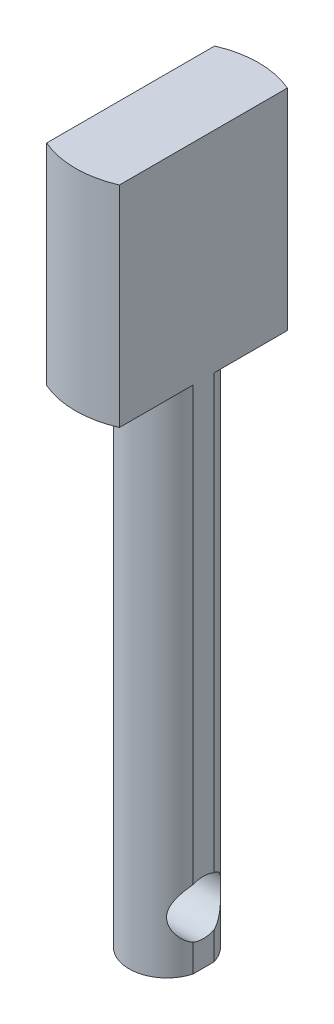
from build123d import *

# Parameters (mm, degrees)
SKETCH1_R               = 2.525
BOSS_EXTRUDE1_DEPTH     = 48
SKETCH2_R               = 6.1
BOSS_EXTRUDE2_DEPTH     = 14
SKETCH3_R               = 1.8
CUT_EXTRUDE1_DEPTH      = 7.1
CUT_EXTRUDE1_DEPTH_BACK = 7.1
SKETCH4_OUTSIDE_W       = 24.402
SKETCH4_OUTSIDE_H       = 24.402
SKETCH4_OUTSIDE_W_2     = 4.85
SKETCH4_OUTSIDE_H_2     = 23.377611606
CUT_EXTRUDE4_DEPTH      = 49


with BuildPart() as part:
    # Sketch1 → Boss-Extrude1 (new body)
    with BuildSketch(Plane(origin=(0, 0, 0), x_dir=(1, 0, 0), z_dir=(0, 1, 0))):
        Circle(SKETCH1_R)
    extrude(amount=BOSS_EXTRUDE1_DEPTH)

    # Sketch2 → Boss-Extrude2 (add)
    with BuildSketch(Plane(origin=(0, 48, 0), x_dir=(1, 0, 0), z_dir=(0, 1, 0))):
        Circle(SKETCH2_R)
    extrude(amount=-BOSS_EXTRUDE2_DEPTH)

    # Sketch3 → Cut-Extrude1 (cut, two sides)
    with BuildSketch(Plane(origin=(0, 0, 0), x_dir=(0, 0, -1), z_dir=(1, 0, 0))) as cut_extrude1_sk:
        with Locations((0, 3.5)):
            Circle(SKETCH3_R)
    extrude(amount=CUT_EXTRUDE1_DEPTH, mode=Mode.SUBTRACT)
    extrude(cut_extrude1_sk.sketch, amount=-CUT_EXTRUDE1_DEPTH_BACK, mode=Mode.SUBTRACT)

    # Sketch4 outside → Cut-Extrude4 (cut, through all)
    with BuildSketch(Plane(origin=(0, 0, 0), x_dir=(1, 0, 0), z_dir=(0, 1, 0))):
        Rectangle(SKETCH4_OUTSIDE_W, SKETCH4_OUTSIDE_H)
        Rectangle(SKETCH4_OUTSIDE_W_2, SKETCH4_OUTSIDE_H_2, mode=Mode.SUBTRACT)
    extrude(amount=CUT_EXTRUDE4_DEPTH, mode=Mode.SUBTRACT)


solid = part.part
